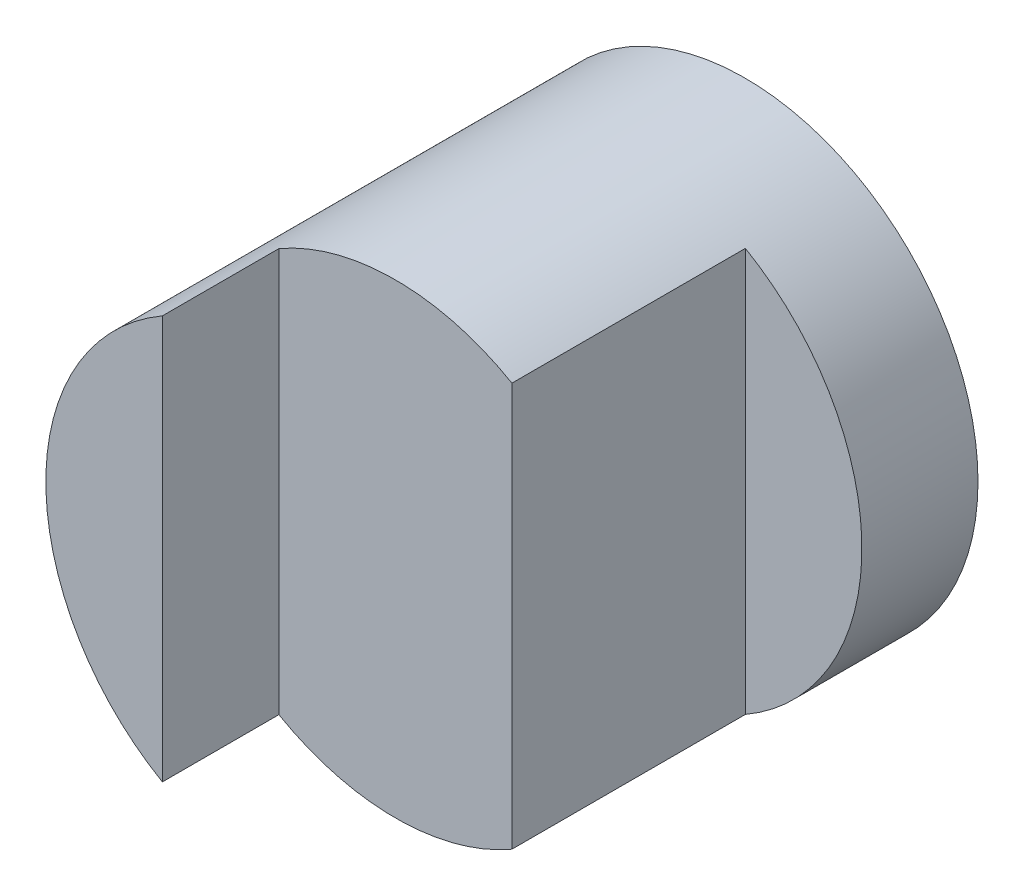
from build123d import *

# Parameters (mm, degrees)
SKETCH1_R           = 2
BOSS_EXTRUDE1_DEPTH = 4
CUT_EXTRUDE2_DEPTH  = 2


with BuildPart() as part:
    # Sketch1 → Boss-Extrude1 (new body)
    with BuildSketch(Plane.XY):
        Circle(SKETCH1_R)
    extrude(amount=BOSS_EXTRUDE1_DEPTH)

    # Sketch2 → Cut-Extrude2 (cut, symmetric)
    with BuildSketch(Plane(origin=(0, 0, 0), x_dir=(1, 0, 0), z_dir=(0, 1, 0))):
        Polygon((-1, -3), (1, -3), (1, -0.996424707), (2, -0.996424707), (2, -4), (-1, -4), align=None)
    extrude(amount=CUT_EXTRUDE2_DEPTH, both=True, mode=Mode.SUBTRACT)


solid = part.part
